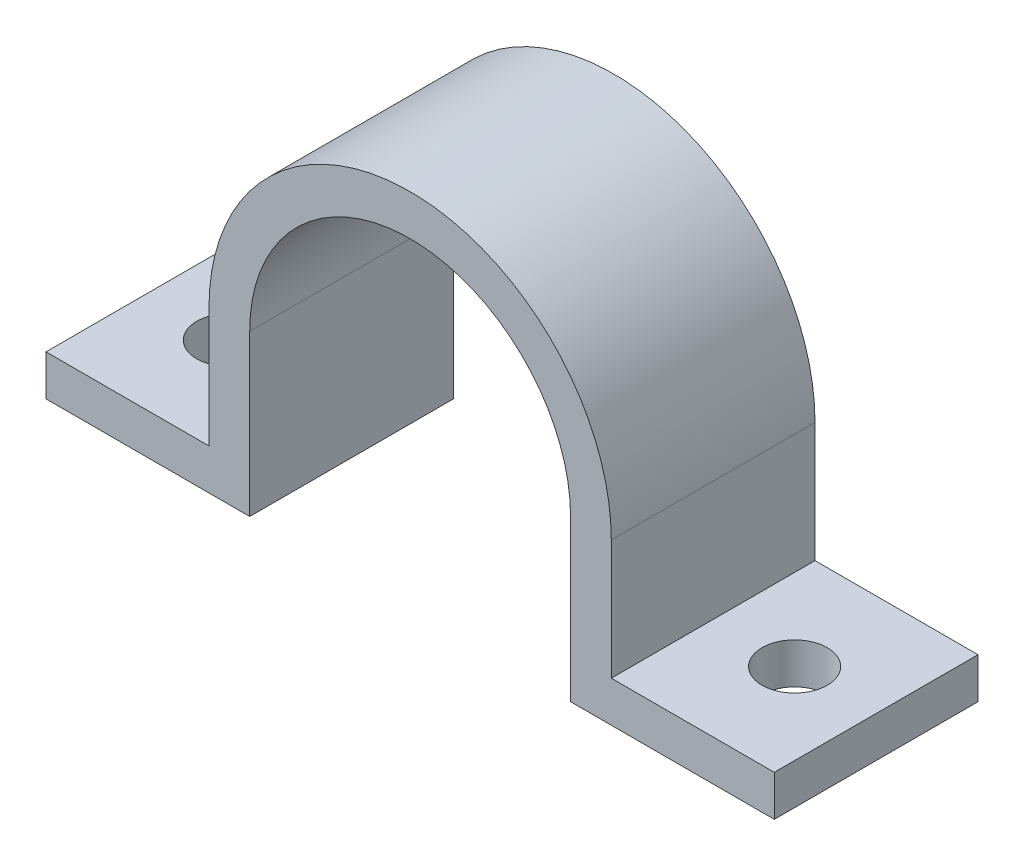
from build123d import *

# Parameters (mm, degrees)
BOSS_EXTRUDE1_DEPTH = 12.7
SKETCH3_R           = 2.032
CUT_EXTRUDE1_DEPTH  = 12.7


with BuildPart() as part:
    # Sketch1 → Boss-Extrude1 (new body)
    with BuildSketch(Plane.XY):
        with BuildLine():
            Line((-9.163521891, -0.002572295), (-9.163521891, -10.002577695))
            Line((-9.163521891, -10.002577695), (-21.863521891, -10.002577695))
            Line((-21.863521891, -10.002577695), (-21.863521891, -7.462577695))
            Line((-21.863521891, -7.462577695), (-11.703521891, -7.462577695))
            Line((-11.703521891, -7.462577695), (-11.703521891, -0.002572295))
            ThreePointArc((-11.703521891, -0.002572295), (0.836483509, 12.537433105), (13.376488909, -0.002572295))
            Line((13.376488909, -0.002572295), (13.376488909, -7.462577695))
            Line((13.376488909, -7.462577695), (23.536488909, -7.462577695))
            Line((23.536488909, -7.462577695), (23.536488909, -10.002577695))
            Line((23.536488909, -10.002577695), (10.836488909, -10.002577695))
            Line((10.836488909, -10.002577695), (10.836488909, -0.002572295))
            ThreePointArc((10.836488909, -0.002572295), (0.836483509, 9.997433105), (-9.163521891, -0.002572295))
        make_face()
    extrude(amount=BOSS_EXTRUDE1_DEPTH)

    # Sketch3 → Cut-Extrude1 (cut)
    with BuildSketch(Plane(origin=(0, -7.462577695, 0), x_dir=(1, 0, 0), z_dir=(0, 1, 0))):
        with Locations((-16.783521891, -6.35)):
            Circle(SKETCH3_R)
        with Locations((18.456488909, -6.35)):
            Circle(SKETCH3_R)
    extrude(amount=-CUT_EXTRUDE1_DEPTH, mode=Mode.SUBTRACT)


solid = part.part
